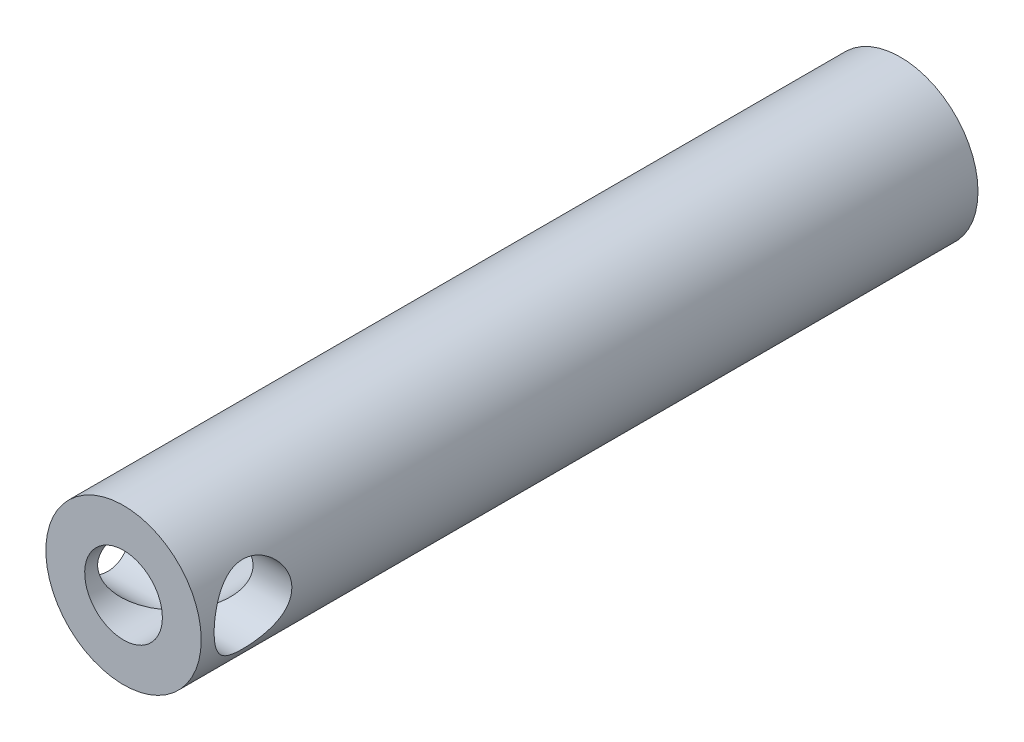
from build123d import *

# Parameters (mm, degrees)
SKETCH1_R               = 15
SKETCH1_R_2             = 7.5
BOSS_EXTRUDE1_DEPTH     = 150
SKETCH2_R               = 7.5
CUT_EXTRUDE2_DEPTH      = 16
CUT_EXTRUDE2_DEPTH_BACK = 16


with BuildPart() as part:
    # Sketch1 → Boss-Extrude1 (new body)
    with BuildSketch(Plane.XY):
        Circle(SKETCH1_R)
        Circle(SKETCH1_R_2, mode=Mode.SUBTRACT)
    extrude(amount=BOSS_EXTRUDE1_DEPTH)

    # Sketch2 → Cut-Extrude2 (cut, two sides)
    with BuildSketch(Plane(origin=(0, 0, 0), x_dir=(0, 0, -1), z_dir=(1, 0, 0))) as cut_extrude2_sk:
        with Locations((-140, 0)):
            Circle(SKETCH2_R)
    extrude(amount=CUT_EXTRUDE2_DEPTH, mode=Mode.SUBTRACT)
    extrude(cut_extrude2_sk.sketch, amount=-CUT_EXTRUDE2_DEPTH_BACK, mode=Mode.SUBTRACT)


solid = part.part
